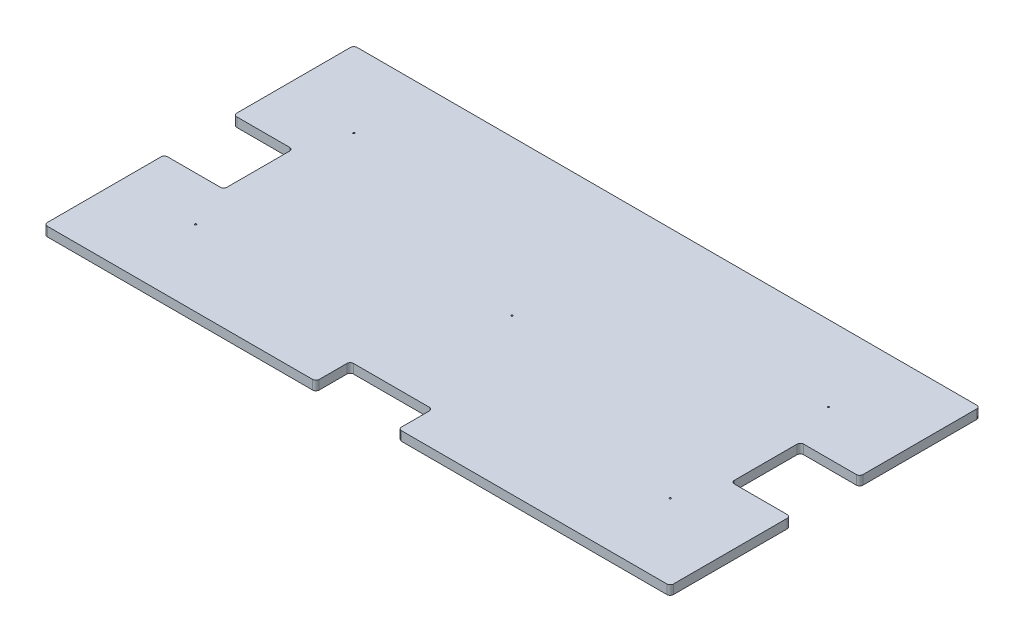
from build123d import *

# Parameters (mm, degrees)
SKETCH1_W                    = 1206.5
SKETCH1_H                    = 596.9
BOSS_EXTRUDE1_DEPTH          = 17.78
F_1_8_0_125_DIAMETER_HOLE1_D = 3.175
FILLET1_R                    = 6.35
SKETCH4_W                    = 158.75
SKETCH4_H                    = 66.04
SKETCH4_W_2                  = 114.3
SKETCH4_H_2                  = 133.35
CUT_EXTRUDE1_DEPTH           = 18.78
FILLET2_R                    = 6.35


with BuildPart() as part:
    # Sketch1 → Boss-Extrude1 (new body)
    with BuildSketch(Plane(origin=(0, 0, 0), x_dir=(1, 0, 0), z_dir=(0, 1, 0))):
        Rectangle(SKETCH1_W, SKETCH1_H)
    extrude(amount=BOSS_EXTRUDE1_DEPTH)

    # 1/8 (0.125) Diameter Hole1 (through all)
    with Locations(Plane(origin=(0, 17.78, 0), x_dir=(1, 0, 0), z_dir=(0, 1, 0))):
        with Locations((0, 0), (457.2, 152.4), (-457.2, -152.4), (-457.2, 152.4), (457.2, -152.4)):
            Hole(F_1_8_0_125_DIAMETER_HOLE1_D / 2)

    # Fillet1
    fillet1_edges = [part.edges().sort_by_distance(p)[0] for p in [
        (603.25, 8.89, 298.45),
        (-603.25, 8.89, 298.45),
        (-603.25, 8.89, -298.45),
        (603.25, 8.89, -298.45),
    ]]
    fillet(fillet1_edges, radius=FILLET1_R)

    # Sketch4 → Cut-Extrude1 (cut, through all)
    with BuildSketch(Plane(origin=(0, 17.78, 0), x_dir=(1, 0, 0), z_dir=(0, 1, 0))):
        with Locations((0, -265.43)):
            Rectangle(SKETCH4_W, SKETCH4_H)
        with Locations((-546.1, 0)):
            Rectangle(SKETCH4_W_2, SKETCH4_H_2)
        with Locations((546.1, 0)):
            Rectangle(SKETCH4_W_2, SKETCH4_H_2)
    extrude(amount=-CUT_EXTRUDE1_DEPTH, mode=Mode.SUBTRACT)

    # Fillet2
    fillet2_edges = [part.edges().sort_by_distance(p)[0] for p in [
        (-488.95, 8.89, 66.675),
        (603.25, 8.89, -66.675),
        (603.25, 8.89, 66.675),
        (488.95, 8.89, 66.675),
        (488.95, 8.89, -66.675),
        (79.375, 8.89, 232.41),
        (79.375, 8.89, 298.45),
        (-79.375, 8.89, 298.45),
        (-79.375, 8.89, 232.41),
        (-603.25, 8.89, 66.675),
        (-603.25, 8.89, -66.675),
        (-488.95, 8.89, -66.675),
    ]]
    fillet(fillet2_edges, radius=FILLET2_R)


solid = part.part
